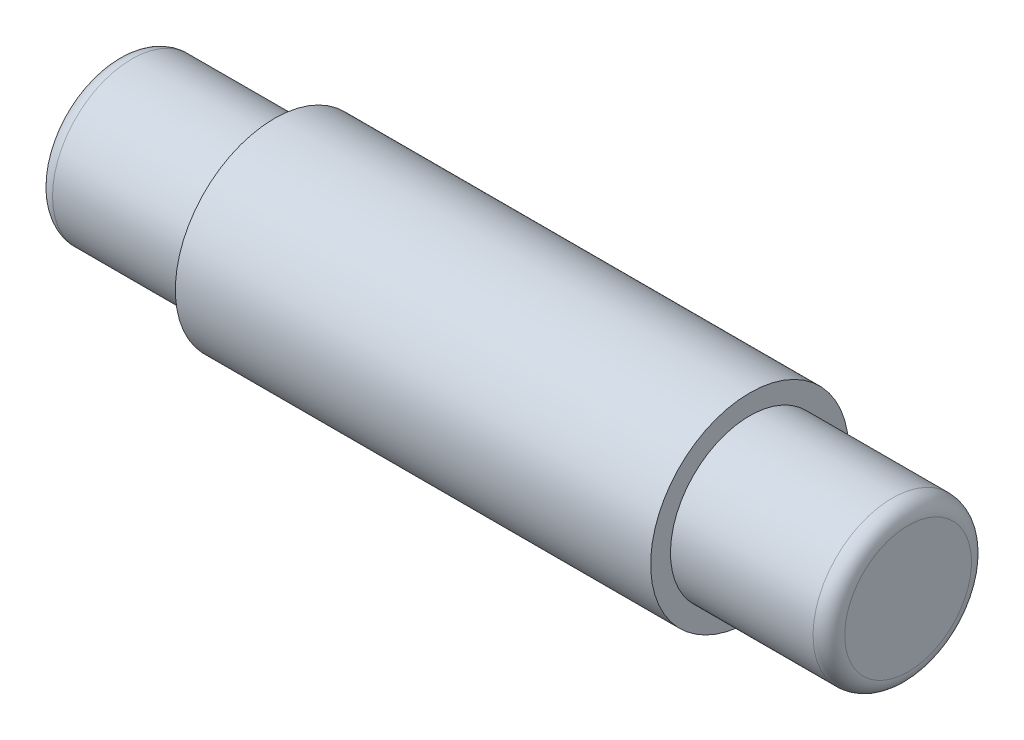
from build123d import *

# Parameters (mm, degrees)
FILLET1_R = 2.54


with BuildPart() as part:
    # Sketch1 → Revolve2 (revolve)
    with BuildSketch(Plane.XY):
        Polygon((-63.5, 0), (63.5, 0), (63.5, 12.7), (38.1, 12.7), (38.1, 15.875), (-38.1, 15.875), (-38.1, 12.7), (-63.5, 12.7), align=None)
    revolve(axis=Axis((-63.5, 0, 0), (1, 0, 0)))

    # Fillet1
    fillet1_edges = [part.edges().sort_by_distance(p)[0] for p in [
        (-63.5, -12.7, 0),
        (63.5, -12.7, 0),
    ]]
    fillet(fillet1_edges, radius=FILLET1_R)


solid = part.part
